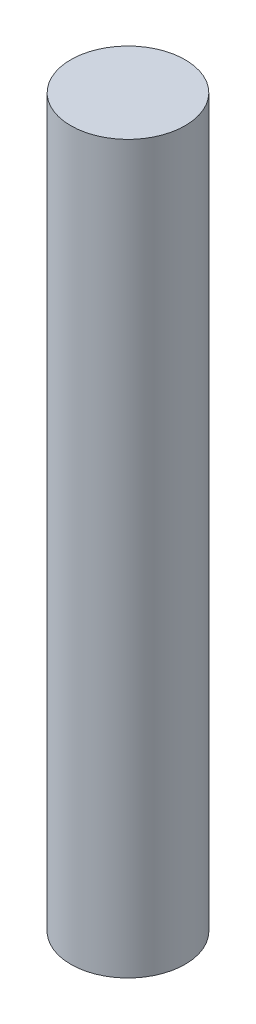
from build123d import *

# Parameters (mm, degrees)
SKETCH1_R           = 4
BOSS_EXTRUDE1_DEPTH = 50.8


with BuildPart() as part:
    # Sketch1 → Boss-Extrude1 (new body)
    with BuildSketch(Plane(origin=(0, 0, 0), x_dir=(1, 0, 0), z_dir=(0, 1, 0))):
        Circle(SKETCH1_R)
    extrude(amount=BOSS_EXTRUDE1_DEPTH)


solid = part.part
